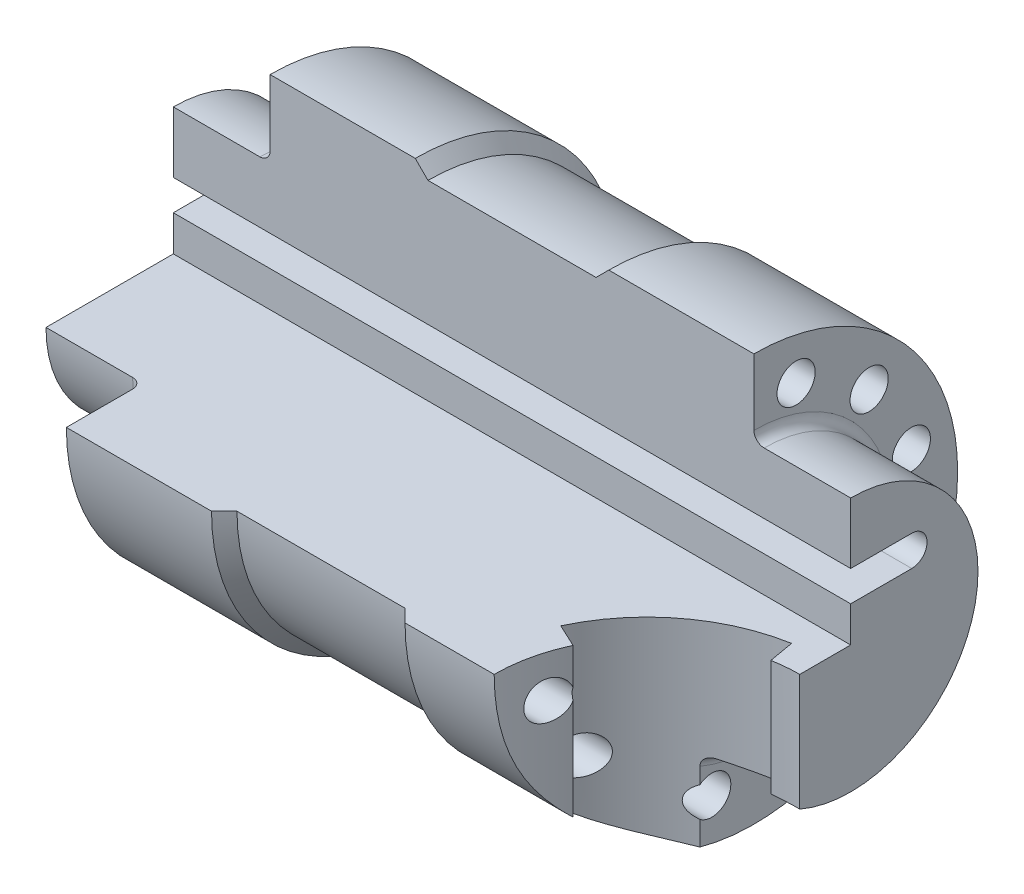
from build123d import *

# Parameters (mm, degrees)
ZAOKR_GLENIE1_R            = 2
WYTNIJ_WYCI_GNI_CIE1_DEPTH = 134
SZKIC4_R                   = 3.75
WYTNIJ_WYCI_GNI_CIE2_DEPTH = 115
SZYK_KO_OWY1_COUNT         = 9
SZYK_KO_OWY1_ANGLE         = 240
WYTNIJ_WYCI_GNI_CIE3_DEPTH = 41
WYTNIJ_WYCI_GNI_CIE4_DEPTH = 10
ZAOKR_GLENIE2_R            = 1
ZAOKR_GLENIE3_R            = 1


with BuildPart() as part:
    # Szkic2 → Obrót1 (revolve)
    with BuildSketch(Plane.XY):
        Polygon((0, 0), (0, 25), (19, 25), (19, 40), (47.5, 40), (50, 37.5), (83, 37.5), (85.5, 40), (114, 40), (114, 25), (133, 25), (133, 0), align=None)
    revolve(axis=Axis((133, 0, 0), (-1, 0, 0)))

    # Zaokrąglenie1
    zaokr_glenie1_edges = [part.edges().sort_by_distance(p)[0] for p in [
        (114, -25, 0),
        (19, -25, 0),
    ]]
    fillet(zaokr_glenie1_edges, radius=ZAOKR_GLENIE1_R)

    # Szkic3 → Wytnij-wyciągnięcie1 (cut, through all)
    with BuildSketch(Plane.ZY):
        with BuildLine():
            Line((0, 0), (0, 7))
            Line((0, 7), (-12, 7))
            ThreePointArc((-12, 7), (-15, 10), (-12, 13))
            Line((-12, 13), (0, 13))
            Line((0, 13), (0, 40))
            ThreePointArc((0, 40), (28.284271247, 28.284271247), (40, 0))
            Line((40, 0), (0, 0))
        make_face()
    extrude(amount=-WYTNIJ_WYCI_GNI_CIE1_DEPTH, mode=Mode.SUBTRACT)

    # Szkic4 → Wytnij-wyciągnięcie2 (cut, through all)
    with BuildSketch(Plane.ZY.offset(-19)):
        with Locations((-8.282209443, 30.909626441)):
            Circle(SZKIC4_R)
    wytnij_wyci_gni_cie2 = extrude(amount=-WYTNIJ_WYCI_GNI_CIE2_DEPTH, mode=Mode.SUBTRACT)

    # Szyk kołowy1: Wytnij-wyciągnięcie2 ×9 about axis
    szyk_ko_owy1_axis = Axis((0, 0, 0), (-1, 0, 0))
    for i in range(1, SZYK_KO_OWY1_COUNT):
        add(wytnij_wyci_gni_cie2.rotate(szyk_ko_owy1_axis, i * SZYK_KO_OWY1_ANGLE / (SZYK_KO_OWY1_COUNT - 1)), mode=Mode.SUBTRACT)

    # Szkic5 → Wytnij-wyciągnięcie3 (cut, through all)
    with BuildSketch(Plane(origin=(0, 0, 0), x_dir=(1, 0, 0), z_dir=(0, 1, 0))):
        with BuildLine():
            Line((101.279227454, -25.208360839), (105.810766389, -27.321452148))
            ThreePointArc((105.810766389, -27.321452148), (151.26284287, -63.800600209), (127.79055467, -10.45576741))
            Line((127.79055467, -10.45576741), (126.922313782, -5.531728645))
            ThreePointArc((126.922313782, -5.531728645), (111.693349985, -12.23263309), (101.279227454, -25.208360839))
        make_face()
    extrude(amount=-WYTNIJ_WYCI_GNI_CIE3_DEPTH, mode=Mode.SUBTRACT)

    # Szkic6 → Wytnij-wyciągnięcie4 (cut)
    with BuildSketch(Plane.ZY):
        with BuildLine():
            Line((-19.899748742, 3), (-5, 3))
            ThreePointArc((-5, 3), (-4.292893219, 2.707106781), (-4, 2))
            Line((-4, 2), (-4, -3))
            ThreePointArc((-4, -3), (-3.707106781, -3.707106781), (-3, -4))
            Line((-3, -4), (19.364916731, -4))
            ThreePointArc((19.364916731, -4), (20.155486146, -4.387627564), (20.333162568, -5.25))
            ThreePointArc((20.333162568, -5.25), (-3.685711089, -20.674030419), (-20.894736179, 2.1))
            ThreePointArc((-20.894736179, 2.1), (-20.570569135, 2.741619849), (-19.899748742, 3))
        make_face()
    extrude(amount=-WYTNIJ_WYCI_GNI_CIE4_DEPTH, mode=Mode.SUBTRACT)

    # Zaokrąglenie2
    zaokr_glenie2_edges = [part.edges().sort_by_distance(p)[0] for p in [
        (10, -4.387627564, 20.155486146),
        (10, -20.674030419, -3.685711089),
        (10, 2.741619849, -20.570569135),
        (10, 3, -12.449874371),
        (10, 2.707106781, -4.292893219),
        (10, -0.5, -4),
        (10, -3.707106781, -3.707106781),
        (10, -4, 8.182458366),
    ]]
    fillet(zaokr_glenie2_edges, radius=ZAOKR_GLENIE2_R)

    # Zaokrąglenie3
    zaokr_glenie3_edges = [part.edges().sort_by_distance(p)[0] for p in [
        (0, -4.387627564, 20.155486146),
        (0, -20.674030419, -3.685711089),
        (0, 2.741619849, -20.570569135),
        (0, 3, -12.449874371),
        (0, 2.707106781, -4.292893219),
        (0, -0.5, -4),
        (0, -3.707106781, -3.707106781),
        (0, -4, 8.182458366),
    ]]
    fillet(zaokr_glenie3_edges, radius=ZAOKR_GLENIE3_R)


solid = part.part
